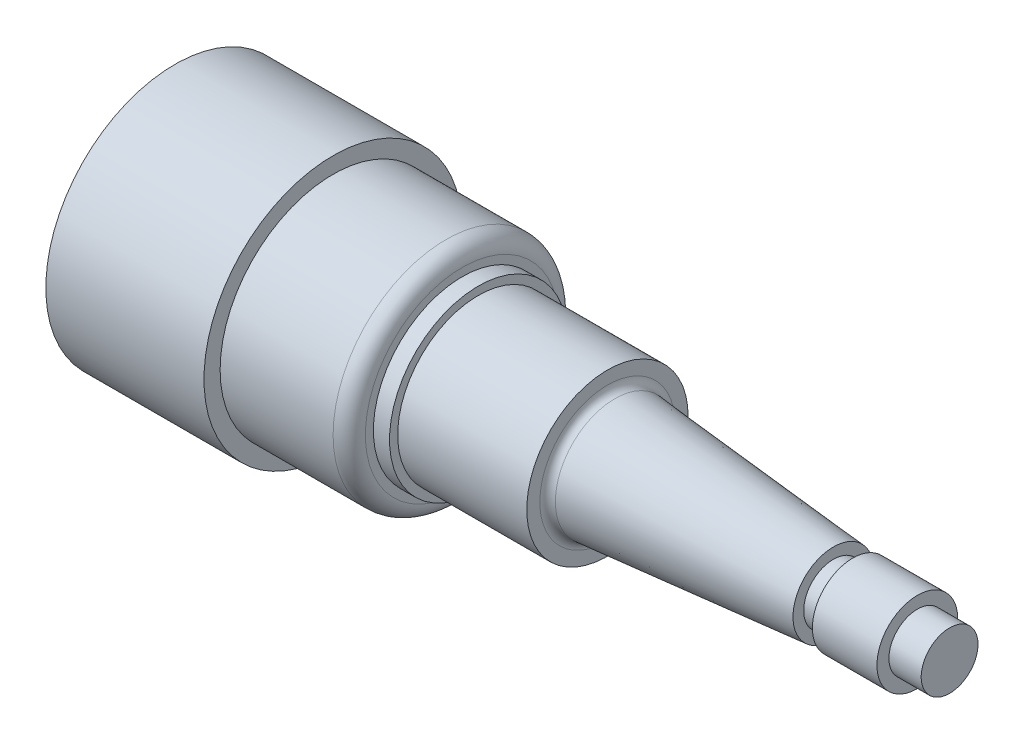
from build123d import *


with BuildPart() as part:
    # Sketch2 → Revolve1 (revolve)
    with BuildSketch(Plane.XY):
        with BuildLine():
            Line((-152.4, 0), (0, 0))
            Line((0, 0), (0, -5.588))
            Line((0, -5.588), (-6.35, -5.588))
            Line((-6.35, -5.588), (-6.35, -7.9502))
            Line((-6.35, -7.9502), (-19.05, -7.9502))
            Line((-19.05, -7.9502), (-19.05, -5.842))
            Line((-19.05, -5.842), (-22.86, -5.842))
            Line((-22.86, -5.842), (-22.86, -7.9502))
            Line((-22.86, -7.9502), (-65.849197896, -11.7094))
            ThreePointArc((-65.849197896, -11.7094), (-66.889567891, -12.222411886), (-67.31, -13.303516767))
            Line((-67.31, -13.303516767), (-67.31, -15.875))
            Line((-67.31, -15.875), (-92.71, -15.875))
            Line((-92.71, -15.875), (-92.71, -17.4752))
            Line((-92.71, -17.4752), (-95.885, -17.4752))
            Line((-95.885, -17.4752), (-95.885, -19.05))
            ThreePointArc((-95.885, -19.05), (-96.81493597, -21.29506403), (-99.06, -22.225))
            Line((-99.06, -22.225), (-121.285, -22.225))
            Line((-121.285, -22.225), (-121.285, -25.4))
            Line((-121.285, -25.4), (-152.4, -25.4))
            Line((-152.4, -25.4), (-152.4, 0))
        make_face()
    revolve(axis=Axis((88.99, 0, 0), (-1, 0, 0)))


solid = part.part
